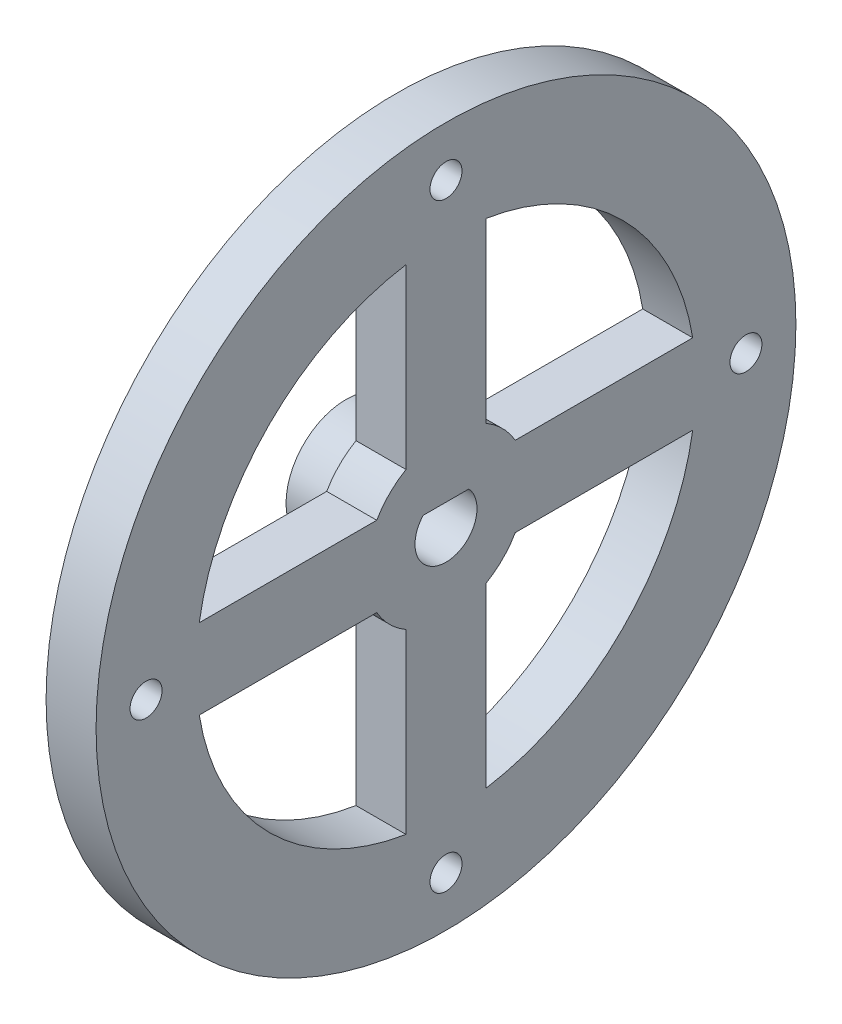
from build123d import *
from build123d.topology import SkipClean

# Parameters (mm, degrees)
SKETCH1_R           = 35
BOSS_EXTRUDE1_DEPTH = 5
SKETCH2_R           = 1.6
CUT_EXTRUDE1_DEPTH  = 50.749371855
SKETCH3_R           = 6
BOSS_EXTRUDE2_DEPTH = 5
SKETCH6_R           = 4
CUT_EXTRUDE2_DEPTH  = 2


with BuildPart() as part:
    # Sketch1 → Boss-Extrude1 (new body)
    with BuildSketch(Plane(origin=(0, 0, 0), x_dir=(0, 0, -1), z_dir=(1, 0, 0))):
        Circle(SKETCH1_R)
        with BuildLine():
            Line((4, 6.92820323), (4, 24.677925359))
            ThreePointArc((4, 24.677925359), (17.67766953, 17.67766953), (24.677925359, 4))
            Line((24.677925359, 4), (6.92820323, 4))
            ThreePointArc((6.92820323, 4), (5.656854249, 5.656854249), (4, 6.92820323))
        make_face(mode=Mode.SUBTRACT)
        with BuildLine():
            Line((-4, 24.677925359), (-4, 6.92820323))
            ThreePointArc((-4, 6.92820323), (-5.656854249, 5.656854249), (-6.92820323, 4))
            Line((-6.92820323, 4), (-24.677925359, 4))
            ThreePointArc((-24.677925359, 4), (-17.67766953, 17.67766953), (-4, 24.677925359))
        make_face(mode=Mode.SUBTRACT)
        with BuildLine():
            Line((-24.677925359, -4), (-6.92820323, -4))
            ThreePointArc((-6.92820323, -4), (-5.656854249, -5.656854249), (-4, -6.92820323))
            Line((-4, -6.92820323), (-4, -24.677925359))
            ThreePointArc((-4, -24.677925359), (-17.67766953, -17.67766953), (-24.677925359, -4))
        make_face(mode=Mode.SUBTRACT)
        with BuildLine():
            Line((4, -24.677925359), (4, -6.92820323))
            ThreePointArc((4, -6.92820323), (5.656854249, -5.656854249), (6.92820323, -4))
            Line((6.92820323, -4), (24.677925359, -4))
            ThreePointArc((24.677925359, -4), (17.67766953, -17.67766953), (4, -24.677925359))
        make_face(mode=Mode.SUBTRACT)
        with BuildLine():
            Line((-2.28035085, 2.1), (2.28035085, 2.1))
            ThreePointArc((2.28035085, 2.1), (0, -3.1), (-2.28035085, 2.1))
        make_face(mode=Mode.SUBTRACT)
    extrude(amount=BOSS_EXTRUDE1_DEPTH)

    # Sketch2 → Cut-Extrude1 (cut, through all)
    with BuildSketch(Plane.ZY):
        with Locations((0, 30)):
            Circle(SKETCH2_R)
        with Locations((30, 0)):
            Circle(SKETCH2_R)
        with Locations((0, -30)):
            Circle(SKETCH2_R)
        with Locations((-30, 0)):
            Circle(SKETCH2_R)
    extrude(amount=-CUT_EXTRUDE1_DEPTH, mode=Mode.SUBTRACT)

    # Sketch3 → Boss-Extrude2 (add)
    with SkipClean():  # the faces are left unmerged after this step: merging them gives an invalid solid
        with BuildSketch(Plane.ZY):
            with Locations(Location((0, 0, 0), (0, 0, 180))):
                Circle(SKETCH3_R)
            with BuildLine():
                Line((-2.28035085, 2.1), (2.28035085, 2.1))
                ThreePointArc((2.28035085, 2.1), (0, -3.1), (-2.28035085, 2.1))
            make_face(mode=Mode.SUBTRACT)
        extrude(amount=BOSS_EXTRUDE2_DEPTH)

    # Sketch6 → Cut-Extrude2 (cut)
    with SkipClean():  # the faces are left unmerged after this step: merging them gives an invalid solid
        with BuildSketch(Plane.ZY):
            with Locations((0, 30)):
                Circle(SKETCH6_R)
            with Locations((30, 0)):
                Circle(SKETCH6_R)
            with Locations((0, -30)):
                Circle(SKETCH6_R)
            with Locations((-30, 0)):
                Circle(SKETCH6_R)
        extrude(amount=-CUT_EXTRUDE2_DEPTH, mode=Mode.SUBTRACT)


solid = part.part
